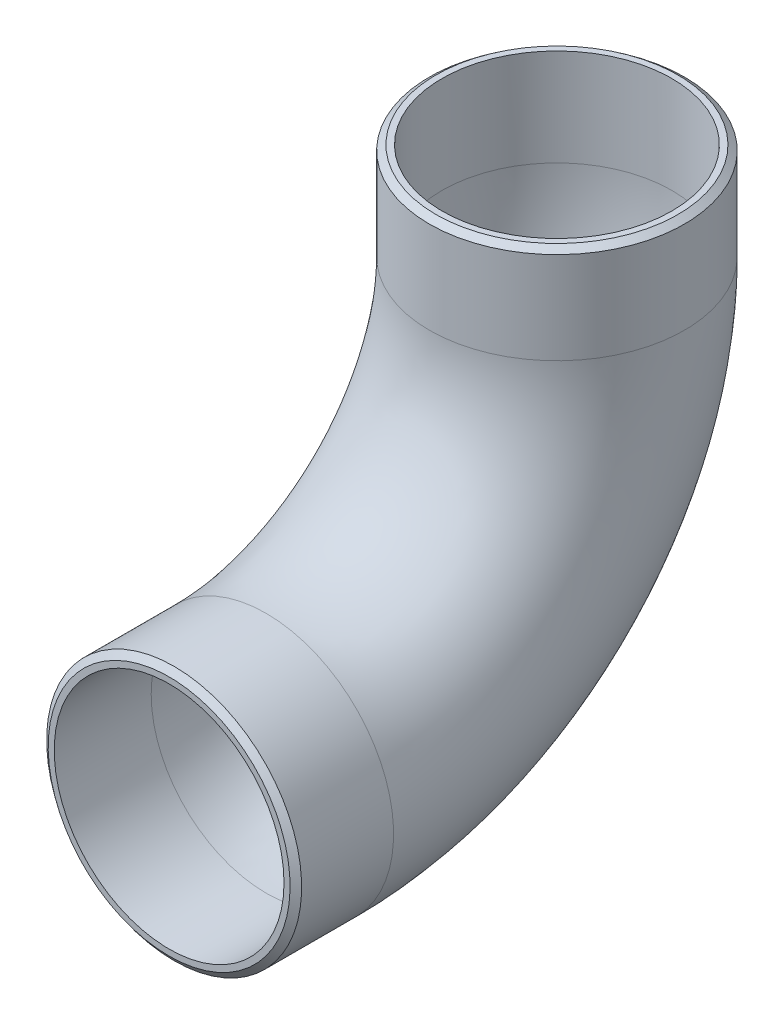
from build123d import *

# Parameters (mm, degrees)
SKETCH2_R    = 16.7005
SKETCH2_R_2  = 15.0495
SCALE1_SCALE = 0.095238095


with BuildPart() as part:
    # Sweep1: sweep along a path in Sketch1
    with BuildLine(Plane(origin=(0, 0, 0), x_dir=(0, 0, -1), z_dir=(1, 0, 0))) as sweep1_path:
        Line((-50.8, 0), (-38.1, 0))
        ThreePointArc((-38.1, 0), (-11.159231637, 11.159231637), (0, 38.1))
        Line((0, 38.1), (0, 50.8))
    # Sketch2 → Sweep1 (sweep)
    with BuildSketch(Plane.XY.offset(50.8)):
        Circle(SKETCH2_R)
        Circle(SKETCH2_R_2, mode=Mode.SUBTRACT)
    sweep(path=sweep1_path.line)

    # Sketch3 → Cut-Revolve1 (revolve, cut)
    with BuildSketch(Plane(origin=(0, 0, 0), x_dir=(0, 1, 0), z_dir=(-1, 0, 0))):
        Polygon((-16.7005, -50.8), (-16.7005, -50.14220894), (-15.84325, -50.8), align=None)
    revolve(axis=Axis((0, 0, 50.8), (0, 0, -1)), mode=Mode.SUBTRACT)

    # Sketch3_4 → Cut-Revolve2 (revolve, cut)
    with BuildSketch(Plane(origin=(0, 0, 0), x_dir=(0, 1, 0), z_dir=(-1, 0, 0))):
        Polygon((50.8, 15.84325), (50.8, 16.7005), (50.14220894, 16.7005), align=None)
    revolve(axis=Axis((0, 50.8, 0), (0, -1, 0)), mode=Mode.SUBTRACT)


with BuildPart() as part_1:
    # Scale1: scaled about (0, 14.816195429, 14.816195429)
    add(part.part.scale(SCALE1_SCALE).moved(Location((0, 13.405129198, 13.405129198))))


solid = part_1.part
